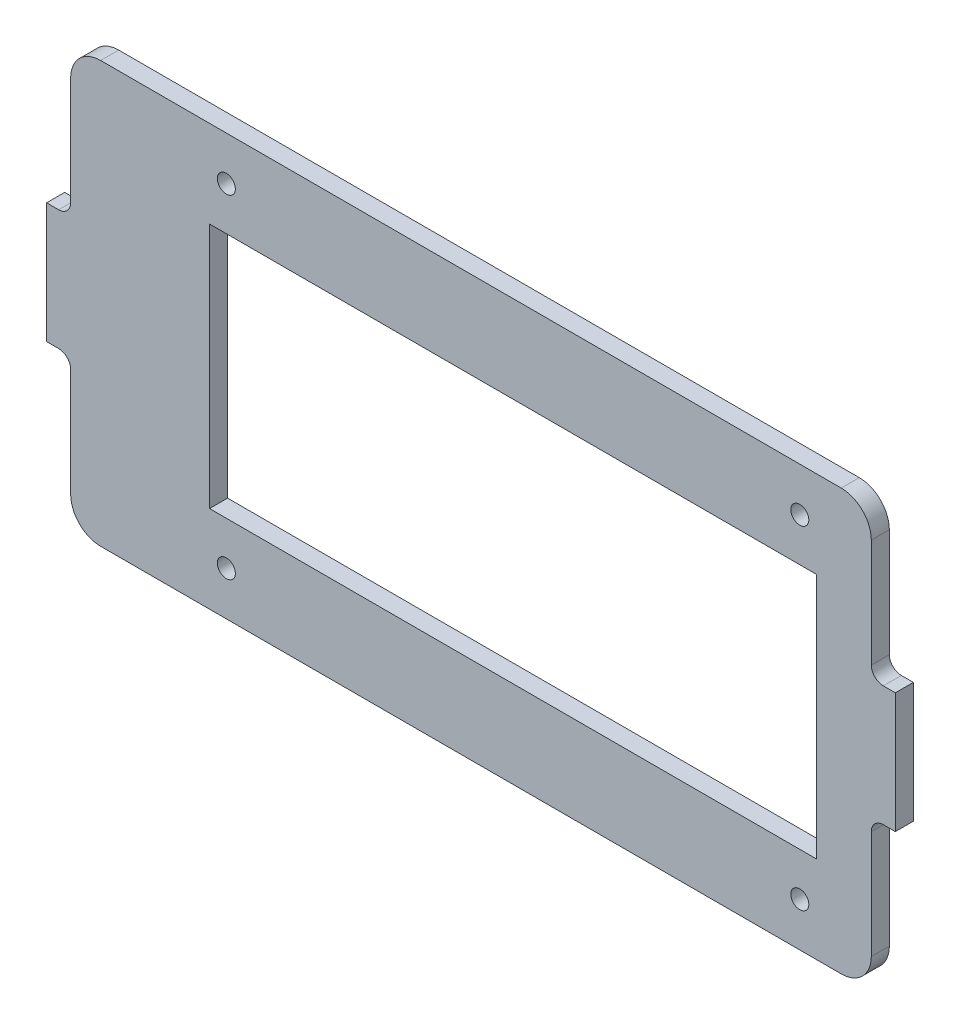
from build123d import *

# Parameters (mm, degrees)
ESQUISSE1_W                       = 101
ESQUISSE1_H                       = 41
BOSS_EXTRU_1_DEPTH                = 3
DIAM_TRE_DU_PER_AGE_3_0_3_1_D     = 3
DIAM_TRE_DU_PER_AGE_3_0_3_1_DEPTH = 3


with BuildPart() as part:
    # Esquisse1 → Boss.-Extru.1 (new body)
    with BuildSketch(Plane.XY):
        with BuildLine():
            Line((66.6, 30), (66.6, 12))
            ThreePointArc((66.6, 12), (67.185786438, 10.585786438), (68.6, 10))
            Line((68.6, 10), (70.6, 10))
            Line((70.6, 10), (70.6, -10))
            Line((70.6, -10), (68.6, -10))
            ThreePointArc((68.6, -10), (67.185786438, -10.585786438), (66.6, -12))
            Line((66.6, -12), (66.6, -30))
            ThreePointArc((66.6, -30), (65.135533906, -33.535533906), (61.6, -35))
            Line((61.6, -35), (-61.6, -35))
            ThreePointArc((-61.6, -35), (-65.135533906, -33.535533906), (-66.6, -30))
            Line((-66.6, -30), (-66.6, -12))
            ThreePointArc((-66.6, -12), (-67.185786438, -10.585786438), (-68.6, -10))
            Line((-68.6, -10), (-70.6, -10))
            Line((-70.6, -10), (-70.6, 10))
            Line((-70.6, 10), (-68.6, 10))
            ThreePointArc((-68.6, 10), (-67.185786438, 10.585786438), (-66.6, 12))
            Line((-66.6, 12), (-66.6, 30))
            ThreePointArc((-66.6, 30), (-65.135533906, 33.535533906), (-61.6, 35))
            Line((-61.6, 35), (61.6, 35))
            ThreePointArc((61.6, 35), (65.135533906, 33.535533906), (66.6, 30))
        make_face()
        with Locations((7, 0)):
            Rectangle(ESQUISSE1_W, ESQUISSE1_H, mode=Mode.SUBTRACT)
    extrude(amount=BOSS_EXTRU_1_DEPTH)

    # Diamètre du perçage Ø3.0 (3)1
    with Locations(Plane.XY.offset(3)):
        with Locations((-40.7, 27.7), (-40.7, -27.7), (54.7, -27.7), (54.7, 27.7)):
            Hole(DIAM_TRE_DU_PER_AGE_3_0_3_1_D / 2, depth=DIAM_TRE_DU_PER_AGE_3_0_3_1_DEPTH)


solid = part.part
